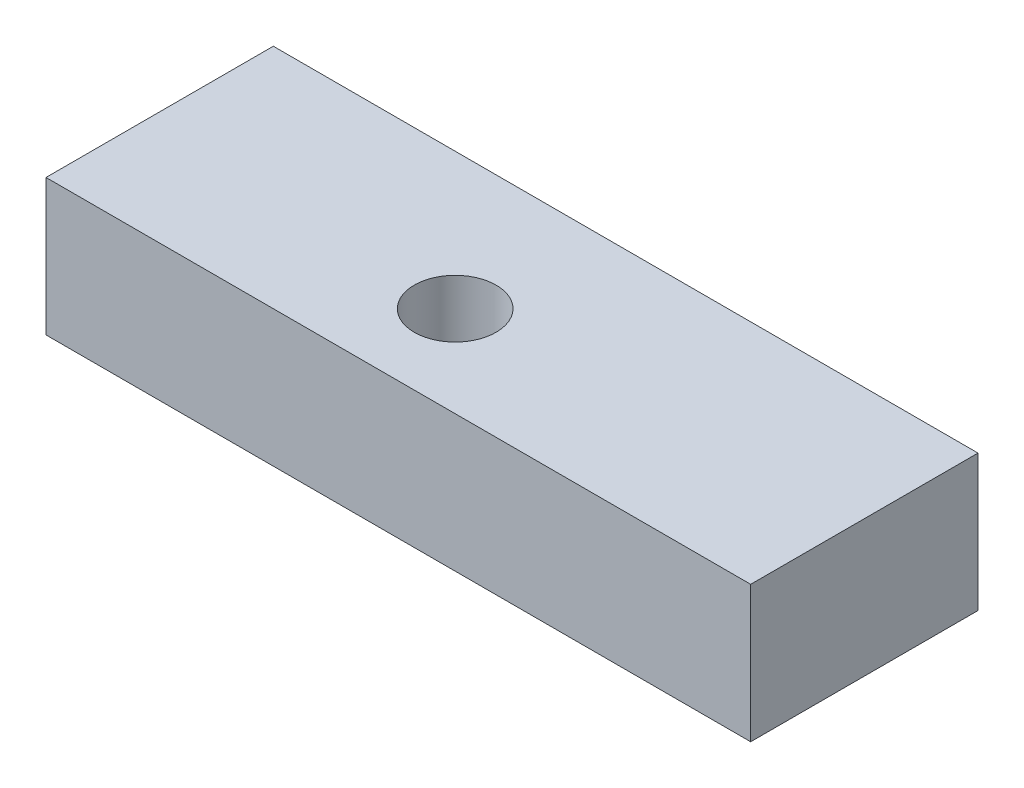
from build123d import *

# Parameters (mm, degrees)
SKETCH1_W           = 155
SKETCH1_H           = 50
SKETCH1_R           = 9
BOSS_EXTRUDE1_DEPTH = 30


with BuildPart() as part:
    # Sketch1 → Boss-Extrude1 (new body)
    with BuildSketch(Plane(origin=(0, 0, 0), x_dir=(1, 0, 0), z_dir=(0, 1, 0))):
        with Locations((7.5, 5)):
            Rectangle(SKETCH1_W, SKETCH1_H)
        Circle(SKETCH1_R, mode=Mode.SUBTRACT)
    extrude(amount=BOSS_EXTRUDE1_DEPTH)


solid = part.part
